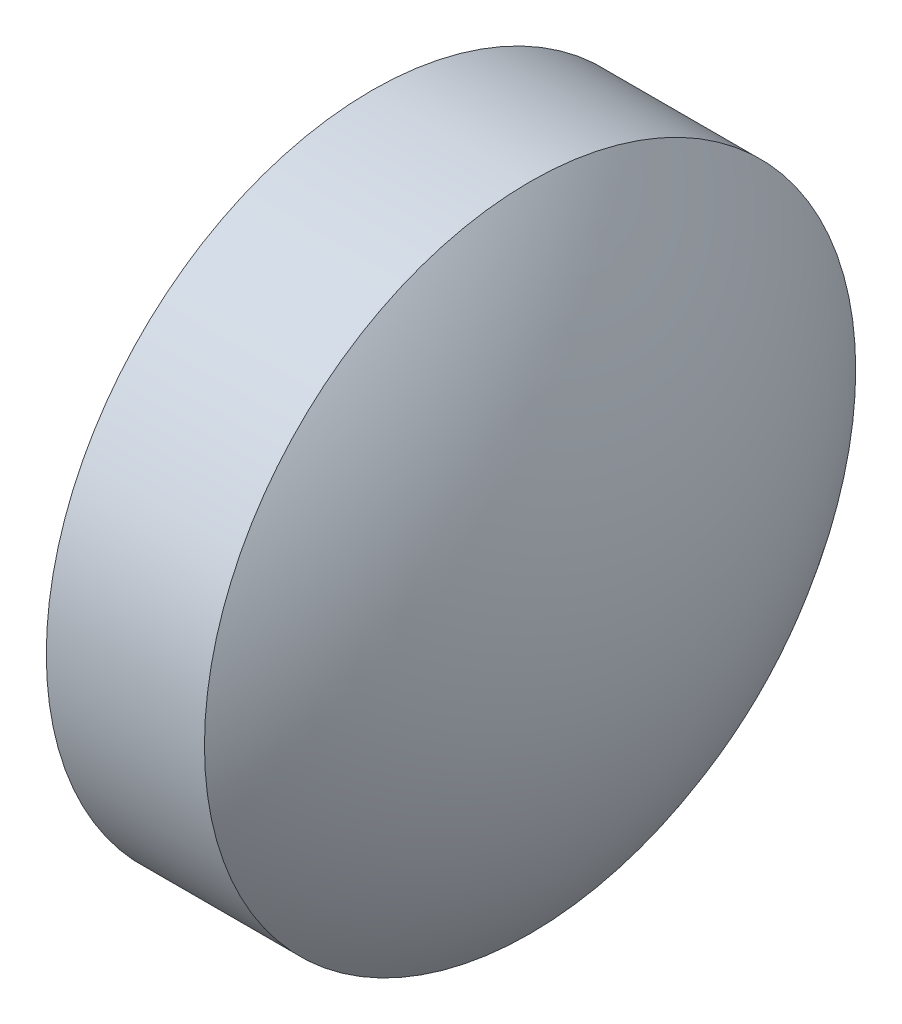
from build123d import *


with BuildPart() as part:
    # 草图1 → 旋转1 (revolve)
    with BuildSketch(Plane.XY):
        with BuildLine():
            Line((351.572017678, 25.047914772), (351.572017678, 28.197914772))
            Line((351.572017678, 28.197914772), (353.102017678, 28.197914772))
            ThreePointArc((353.102017678, 28.197914772), (353.897221466, 26.7113009), (354.172024051, 25.047914772))
            Line((354.172024051, 25.047914772), (351.572017678, 25.047914772))
        make_face()
    revolve(axis=Axis((350.710389509, 25.047914772, 0), (1, 0, 0)))


solid = part.part
